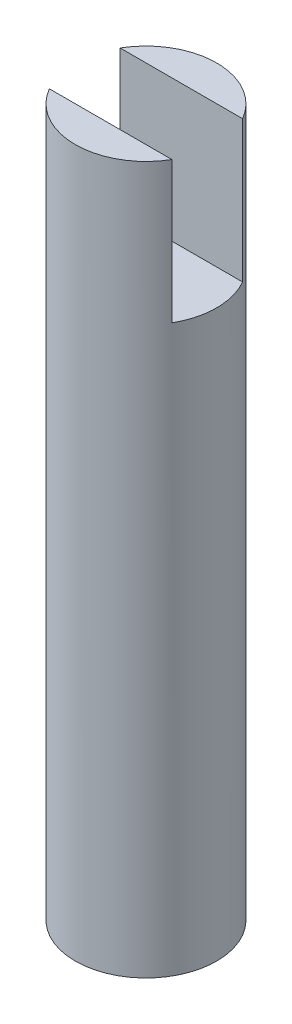
from build123d import *

# Parameters (mm, degrees)
SKETCH1_R                = 5
BOSS_EXTRUDE1_DEPTH      = 5
BOSS_EXTRUDE1_DEPTH_BACK = 45
SKETCH2_W                = 5
SKETCH2_H                = 10
CUT_EXTRUDE1_DEPTH       = 6
CUT_EXTRUDE1_DEPTH_BACK  = 6


with BuildPart() as part:
    # Sketch1 → Boss-Extrude1 (new body, two sides)
    with BuildSketch(Plane(origin=(0, 0, 0), x_dir=(1, 0, 0), z_dir=(0, 1, 0))) as boss_extrude1_sk:
        Circle(SKETCH1_R)
    extrude(amount=BOSS_EXTRUDE1_DEPTH)
    extrude(boss_extrude1_sk.sketch, amount=-BOSS_EXTRUDE1_DEPTH_BACK)

    # Sketch2 → Cut-Extrude1 (cut, two sides)
    with BuildSketch(Plane(origin=(0, 0, 0), x_dir=(0, 0, -1), z_dir=(1, 0, 0))) as cut_extrude1_sk:
        Rectangle(SKETCH2_W, SKETCH2_H)
    extrude(amount=CUT_EXTRUDE1_DEPTH, mode=Mode.SUBTRACT)
    extrude(cut_extrude1_sk.sketch, amount=-CUT_EXTRUDE1_DEPTH_BACK, mode=Mode.SUBTRACT)


solid = part.part
